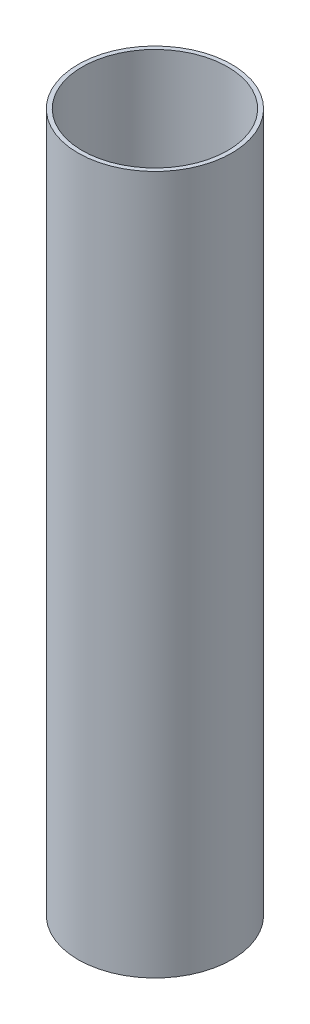
from build123d import *

# Parameters (mm, degrees)
SKETCH_1_R      = 55
SKETCH_1_R_2    = 52
EXTRUDE_1_DEPTH = 500


with BuildPart() as part:
    # Эскиз1 → Вытянуть-Тонкостенный1 (new body)
    with BuildSketch(Plane(origin=(0, 0, 0), x_dir=(1, 0, 0), z_dir=(0, 1, 0))):
        Circle(SKETCH_1_R)
        Circle(SKETCH_1_R_2, mode=Mode.SUBTRACT)
    extrude(amount=EXTRUDE_1_DEPTH)


solid = part.part
